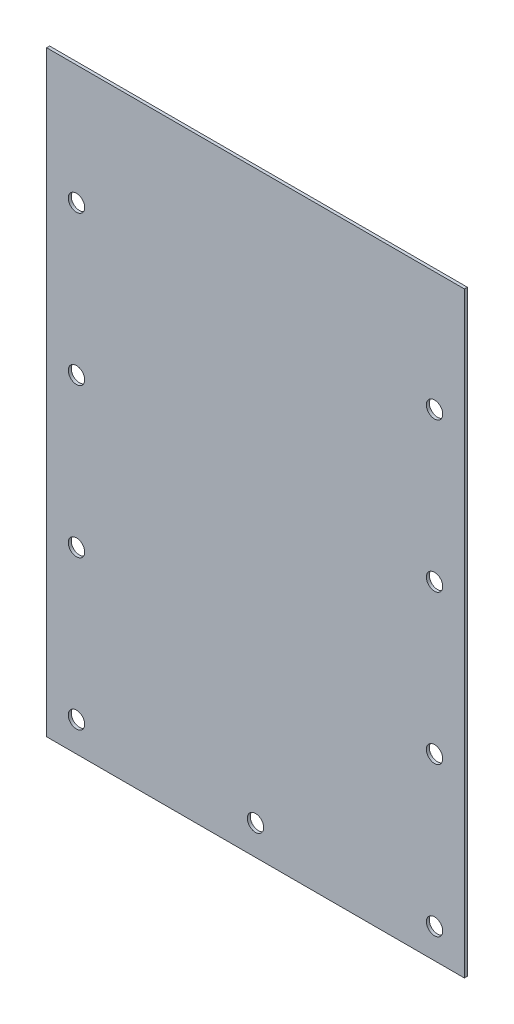
from build123d import *

# Parameters (mm, degrees)
SKETCH_1_W          = 140
SKETCH_1_H          = 220
EXTRUDE_1_DEPTH     = 1
HOLE_WIZARD_M5_1_D  = 5.5
SKETCH_4_W          = 140
SKETCH_4_H          = 20
CUT_EXTRUDE_1_DEPTH = 10


with BuildPart() as part:
    # 스케치1 → 보스-돌출1 (new body)
    with BuildSketch(Plane.XY):
        Rectangle(SKETCH_1_W, SKETCH_1_H)
    extrude(amount=EXTRUDE_1_DEPTH)

    # M5 여유 구멍1 (through all)
    with Locations(Plane(origin=(0, 0, 0), x_dir=(-1, 0, 0), z_dir=(0, 0, -1))):
        with Locations((-60, 100), (0, 100), (60, 100), (60, 50), (60, -50), (60, 0), (60, -100), (-60, 50), (-60, -50), (-60, 0), (-60, -100), (0, -100)):
            Hole(HOLE_WIZARD_M5_1_D / 2)

    # 스케치4 → 컷-돌출1 (cut)
    with BuildSketch(Plane(origin=(0, 0, 0), x_dir=(-1, 0, 0), z_dir=(0, 0, -1))):
        with Locations((0, 100)):
            Rectangle(SKETCH_4_W, SKETCH_4_H)
    extrude(amount=-CUT_EXTRUDE_1_DEPTH, mode=Mode.SUBTRACT)


solid = part.part
